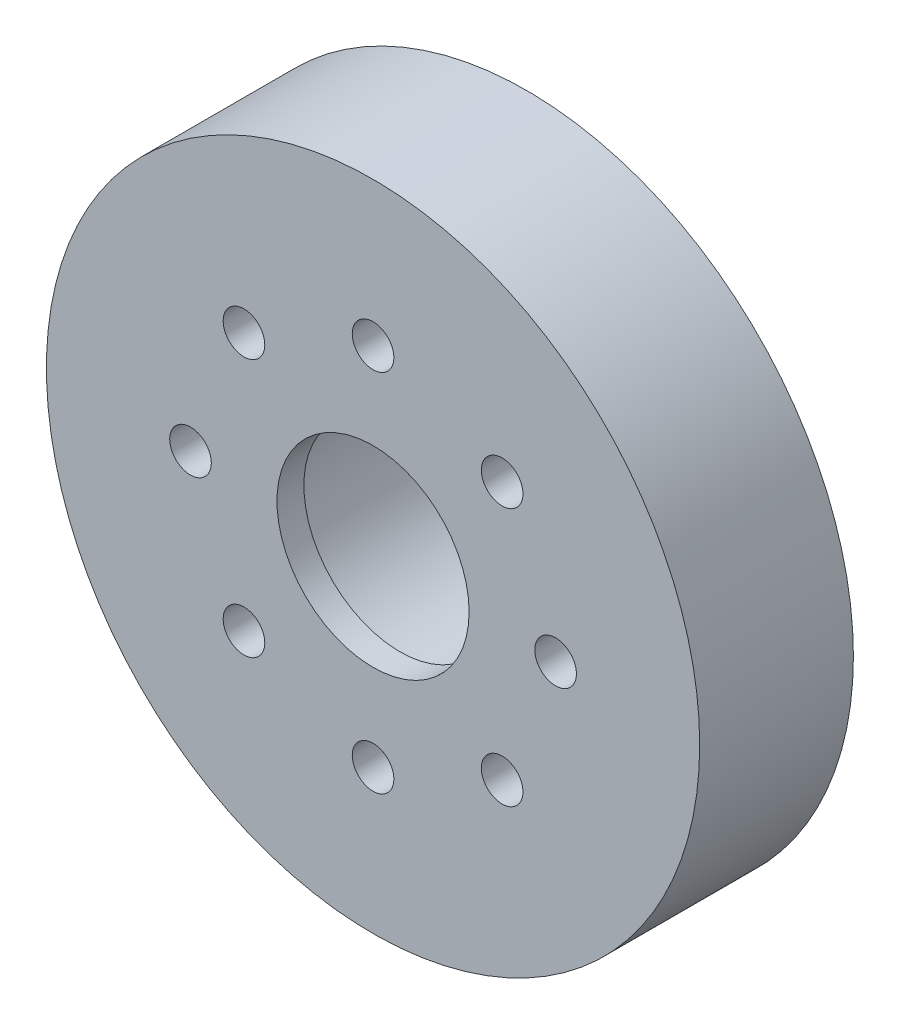
from build123d import *

# Parameters (mm, degrees)
SKETCH1_R                = 43.18
BOSS_EXTRUDE1_DEPTH      = 20.32
M5_CLEARANCE_HOLE1_D     = 5.5
M5_CLEARANCE_HOLE1_DEPTH = 20.32
CIRPATTERN1_COUNT        = 8
SKETCH9_R                = 14.4907
SKETCH9_R_2              = 12.7
BOSS_EXTRUDE2_DEPTH      = 3.556


with BuildPart() as part:
    # Sketch1 → Boss-Extrude1 (new body)
    with BuildSketch(Plane.XY):
        Circle(SKETCH1_R)
    extrude(amount=BOSS_EXTRUDE1_DEPTH)

    # Sketch7 → 1 NPT Tapped Hole2 (revolve, cut)
    with BuildSketch(Plane.YZ):
        Polygon((0, 0), (0, 20.32), (14.4907, 20.32), (14.4907, 16.764), (15.22797859, 16.764), (15.7299152, 0), align=None)
    revolve(axis=Axis((0, 0, -6.35), (0, 0, 1)), mode=Mode.SUBTRACT)

    # M5 Clearance Hole1
    with Locations(Plane(origin=(0, 0, 0), x_dir=(-1, 0, 0), z_dir=(0, 0, -1))):
        with Locations((0, 24.13)):
            m5_clearance_hole1 = Hole(M5_CLEARANCE_HOLE1_D / 2, depth=M5_CLEARANCE_HOLE1_DEPTH)

    # CirPattern1: M5 Clearance Hole1 ×8 about axis
    cirpattern1_axis = Axis((0, 0, 0), (0, 0, 1))
    for i in range(1, CIRPATTERN1_COUNT):
        add(m5_clearance_hole1.rotate(cirpattern1_axis, i * 360 / CIRPATTERN1_COUNT), mode=Mode.SUBTRACT)

    # Sketch9 → Boss-Extrude2 (add)
    with BuildSketch(Plane.XY.offset(20.32)):
        Circle(SKETCH9_R)
        Circle(SKETCH9_R_2, mode=Mode.SUBTRACT)
    extrude(amount=-BOSS_EXTRUDE2_DEPTH)


solid = part.part
